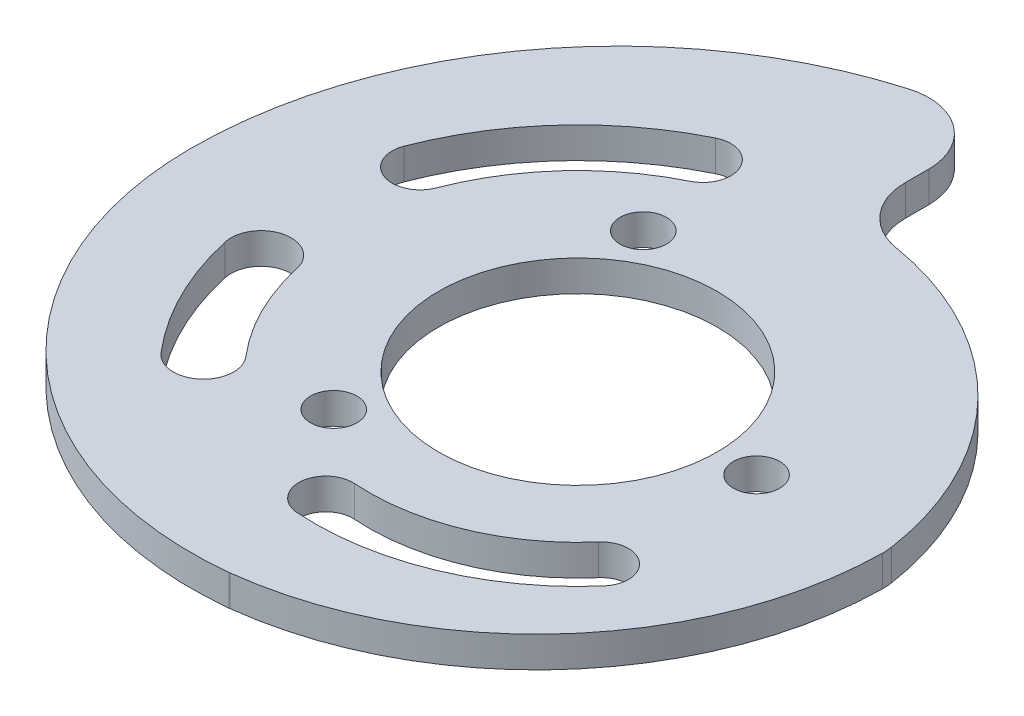
from build123d import *

# Parameters (mm, degrees)
BOSS_EXTRUDE1_DEPTH = 2
SKETCH2_R           = 9
CUT_EXTRUDE1_DEPTH  = 3
FILLET1_R           = 4
SKETCH4_R           = 1.5
CUT_EXTRUDE2_DEPTH  = 3.0000001
CUT_EXTRUDE3_DEPTH  = 3.0000001


with BuildPart() as part:
    # Sketch1 → Boss-Extrude1 (new body)
    with BuildSketch(Plane(origin=(0, 0, 0), x_dir=(1, 0, 0), z_dir=(0, 1, 0))):
        with BuildLine():
            Line((0, 27.5), (0, 17.5))
            ThreePointArc((0, 17.5), (13.287682266, 12.507351161), (20, 0))
            ThreePointArc((20, 0), (14.277242376, -15.051993223), (0, -22.5))
            ThreePointArc((0, -22.5), (-17.510327053, -16.817030059), (-25, 0))
            ThreePointArc((-25, 0), (-17.815844528, 18.582585934), (0, 27.5))
        make_face()
    extrude(amount=BOSS_EXTRUDE1_DEPTH)

    # Sketch2 → Cut-Extrude1 (cut, through all)
    with BuildSketch(Plane(origin=(0, 2, 0), x_dir=(1, 0, 0), z_dir=(0, 1, 0))):
        Circle(SKETCH2_R)
    extrude(amount=-CUT_EXTRUDE1_DEPTH, mode=Mode.SUBTRACT)

    # Fillet1
    fillet1_edges = [part.edges().sort_by_distance(p)[0] for p in [
        (0, 1, -27.5),
        (0, 1, -17.5),
        (20, 1, 0),
        (0, 1, 22.5),
    ]]
    fillet(fillet1_edges, radius=FILLET1_R)

    # Sketch4 → Cut-Extrude2 (cut, through all)
    with BuildSketch(Plane(origin=(0, 2, 0), x_dir=(1, 0, 0), z_dir=(0, 1, 0))):
        with Locations((-5.773502692, 10)):
            Circle(SKETCH4_R)
        with Locations((11.547005384, 0)):
            Circle(SKETCH4_R)
        with Locations((-5.773502692, -10)):
            Circle(SKETCH4_R)
    extrude(amount=-CUT_EXTRUDE2_DEPTH, mode=Mode.SUBTRACT)

    # Sketch5 → Cut-Extrude3 (cut, through all)
    with BuildSketch(Plane(origin=(0, 2, 0), x_dir=(1, 0, 0), z_dir=(0, 1, 0))):
        with BuildLine():
            ThreePointArc((-18.651783434, -4.132756796), (-17.097956543, -8.522240669), (-14.528379596, -12.405437933))
            ThreePointArc((-14.528379596, -12.405437933), (-11.787650951, -12.621464013), (-11.571624871, -9.880735369))
            ThreePointArc((-11.571624871, -9.880735369), (-13.618252323, -6.787830084), (-14.855850898, -3.291675511))
            ThreePointArc((-14.855850898, -3.291675511), (-17.174357809, -1.814249886), (-18.651783434, -4.132756796))
        make_face()
        with BuildLine():
            ThreePointArc((-1.191040224, -16.957696658), (6.508856337, -15.704039033), (12.837977748, -11.143086651))
            ThreePointArc((12.837977748, -11.143086651), (12.664068084, -8.682433661), (10.203415094, -8.856343325))
            ThreePointArc((10.203415094, -8.856343325), (5.173132739, -12.481313807), (-0.946619322, -13.477700417))
            ThreePointArc((-0.946619322, -13.477700417), (-2.808827894, -15.095488087), (-1.191040224, -16.957696658))
        make_face()
        with BuildLine():
            ThreePointArc((-8.627267861, 17.525882988), (-14.425164825, 13.171975745), (-18.235670183, 7.003331939))
            ThreePointArc((-18.235670183, 7.003331939), (-17.195996196, 4.667190222), (-14.859854479, 5.706864208))
            ThreePointArc((-14.859854479, 5.706864208), (-11.754755816, 10.733559053), (-7.03017458, 14.281464197))
            ThreePointArc((-7.03017458, 14.281464197), (-6.206511825, 16.702220233), (-8.627267861, 17.525882988))
        make_face()
    extrude(amount=-CUT_EXTRUDE3_DEPTH, mode=Mode.SUBTRACT)


solid = part.part
